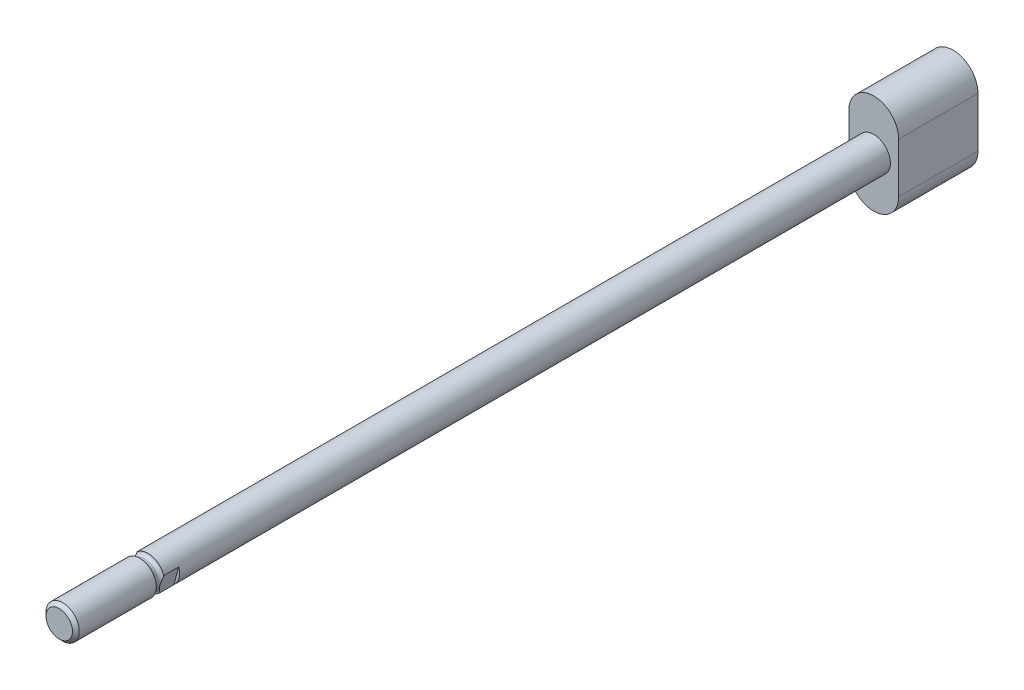
from build123d import *

# Parameters (mm, degrees)
SKETCH2_W           = 145.15
SKETCH2_H           = 3
CUT_EXTRUDE1_DEPTH  = 3.3
BOSS_EXTRUDE1_DEPTH = 14.3


with BuildPart() as part:
    # Sketch1 → Revolve1 (revolve)
    with BuildSketch(Plane(origin=(0, 0, 0), x_dir=(0, 0, -1), z_dir=(1, 0, 0))):
        with BuildLine():
            Line((-23, 0), (-23, 2.3865))
            Line((-23, 2.3865), (-22.3865, 3))
            Line((-22.3865, 3), (-8.5, 3))
            ThreePointArc((-8.5, 3), (-8.324264069, 2.575735931), (-7.9, 2.4))
            Line((-7.9, 2.4), (-7.6, 2.4))
            ThreePointArc((-7.6, 2.4), (-7.175735931, 2.575735931), (-7, 3))
            Line((-7, 3), (-6.5, 3))
            Line((-6.5, 3), (-6.5, 0))
            Line((-6.5, 0), (-23, 0))
        make_face()
    revolve(axis=Axis((0, 0, 6.5), (0, 0, 1)))

    # Sketch2 → Revolve2 (revolve)
    with BuildSketch(Plane(origin=(0, 0, 0), x_dir=(0, 0, -1), z_dir=(1, 0, 0))):
        with Locations((65.575, 1.5)):
            Rectangle(SKETCH2_W, SKETCH2_H)
    revolve(axis=Axis((0, 0, -138.15), (0, 0, 1)))

    # Sketch3 → Cut-Extrude1 (cut)
    with BuildSketch(Plane.XY.offset(4.3)):
        Polygon((-6.447248163, -4.742941189), (3.2120101, -7.33113164), (5.800200551, 2.328126623), (3.385385985, 2.975174236), (1.12071934, -5.476676744), (-3.708909791, -4.182581519), (-1.444243147, 4.269269461), (-3.859057712, 4.916317074), align=None)
    extrude(amount=CUT_EXTRUDE1_DEPTH, mode=Mode.SUBTRACT)

    # Sketch4 → Boss-Extrude1 (add)
    with BuildSketch(Plane.XY.offset(-138.15)):
        with BuildLine():
            Line((4.5, -4.5), (4.5, 4.5))
            ThreePointArc((4.5, 4.5), (3.181980515, 7.681980515), (0, 9))
            ThreePointArc((0, 9), (-3.181980515, 7.681980515), (-4.5, 4.5))
            Line((-4.5, 4.5), (-4.5, -4.5))
            ThreePointArc((-4.5, -4.5), (-3.181980515, -7.681980515), (0, -9))
            ThreePointArc((0, -9), (3.181980515, -7.681980515), (4.5, -4.5))
        make_face()
    extrude(amount=BOSS_EXTRUDE1_DEPTH)


solid = part.part
